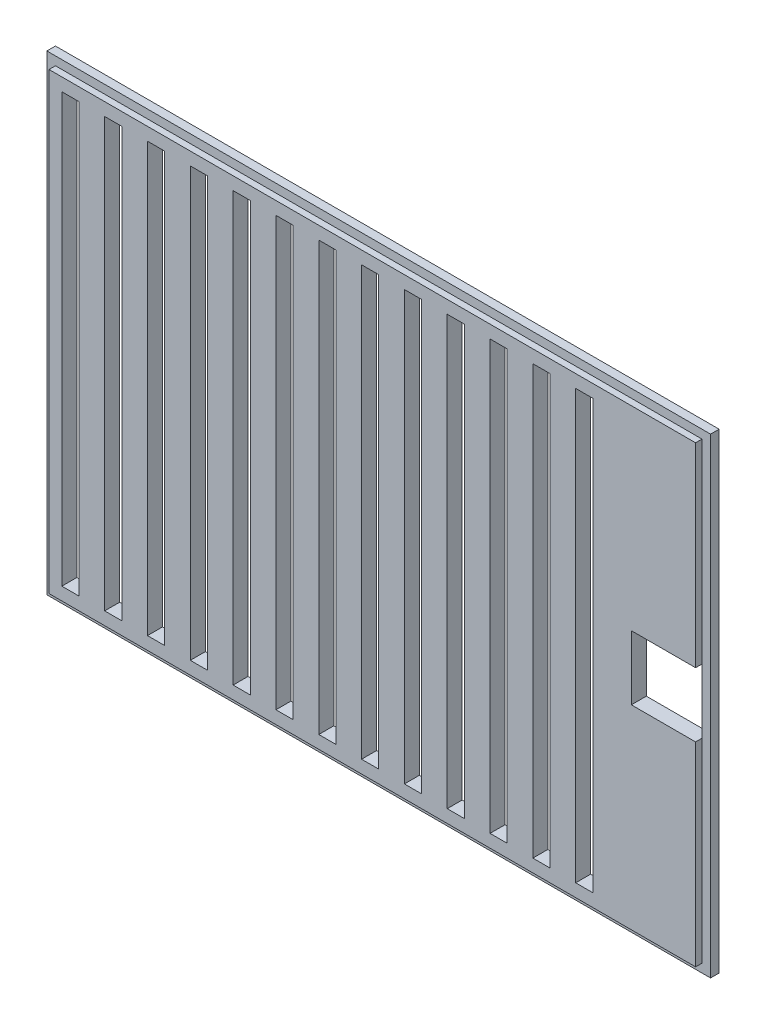
from build123d import *

# Parameters (mm, degrees)
SKETCH1_W           = 155
SKETCH1_H           = 110
BOSS_EXTRUDE1_DEPTH = 2
SKETCH2_W           = 151
SKETCH2_H           = 106
BOSS_EXTRUDE2_DEPTH = 1.5
SKETCH3_W           = 15
SKETCH3_H           = 15
CUT_EXTRUDE2_DEPTH  = 3.5
SKETCH5_W           = 4
SKETCH5_H           = 100
CUT_EXTRUDE3_DEPTH  = 3.5


with BuildPart() as part:
    # Sketch1 → Boss-Extrude1 (new body)
    with BuildSketch(Plane.XY):
        with Locations((77.5, 55)):
            Rectangle(SKETCH1_W, SKETCH1_H)
    extrude(amount=BOSS_EXTRUDE1_DEPTH)

    # Sketch2 → Boss-Extrude2 (add)
    with BuildSketch(Plane.XY.offset(2)):
        with Locations((77.5, 55)):
            Rectangle(SKETCH2_W, SKETCH2_H)
    extrude(amount=BOSS_EXTRUDE2_DEPTH)

    # Sketch3 → Cut-Extrude2 (cut)
    with BuildSketch(Plane.XY.offset(3.5)):
        with Locations((145.5, 55)):
            Rectangle(SKETCH3_W, SKETCH3_H)
    extrude(amount=-CUT_EXTRUDE2_DEPTH, mode=Mode.SUBTRACT)

    # Sketch5 → Cut-Extrude3 (cut)
    with BuildSketch(Plane.XY.offset(3.5)):
        with Locations((17, 55)):
            Rectangle(SKETCH5_W, SKETCH5_H)
        with Locations((7, 55)):
            Rectangle(SKETCH5_W, SKETCH5_H)
        with Locations((27, 55)):
            Rectangle(SKETCH5_W, SKETCH5_H)
        with Locations((37, 55)):
            Rectangle(SKETCH5_W, SKETCH5_H)
        with Locations((47, 55)):
            Rectangle(SKETCH5_W, SKETCH5_H)
        with Locations((57, 55)):
            Rectangle(SKETCH5_W, SKETCH5_H)
        with Locations((67, 55)):
            Rectangle(SKETCH5_W, SKETCH5_H)
        with Locations((77, 55)):
            Rectangle(SKETCH5_W, SKETCH5_H)
        with Locations((87, 55)):
            Rectangle(SKETCH5_W, SKETCH5_H)
        with Locations((97, 55)):
            Rectangle(SKETCH5_W, SKETCH5_H)
        with Locations((107, 55)):
            Rectangle(SKETCH5_W, SKETCH5_H)
        with Locations((117, 55)):
            Rectangle(SKETCH5_W, SKETCH5_H)
        with Locations((127, 55)):
            Rectangle(SKETCH5_W, SKETCH5_H)
    extrude(amount=-CUT_EXTRUDE3_DEPTH, mode=Mode.SUBTRACT)


solid = part.part
